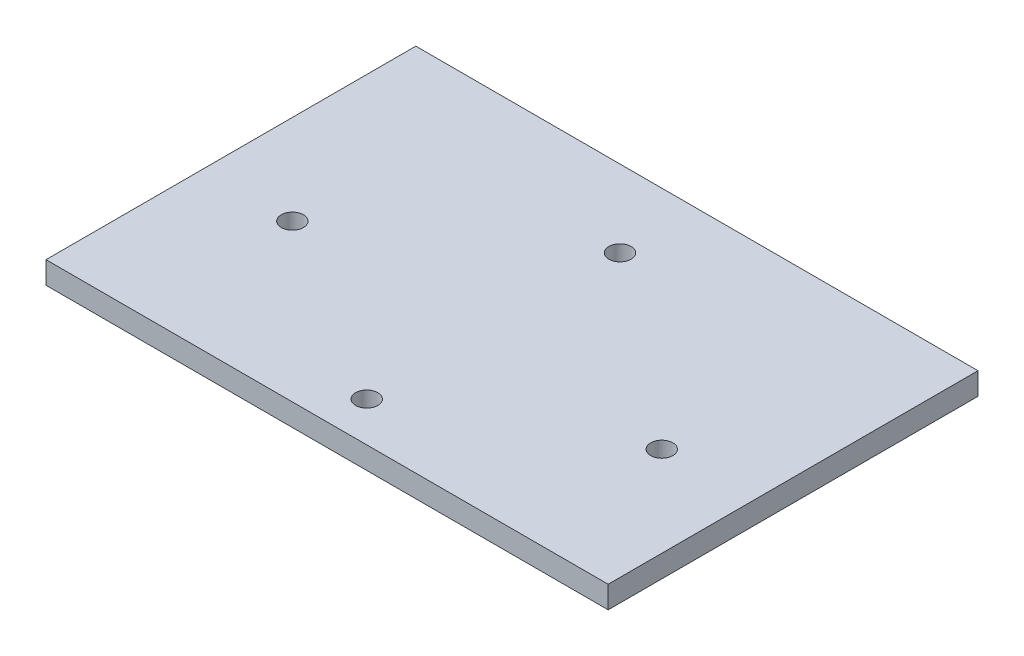
from build123d import *

# Parameters (mm, degrees)
SKETCH2_W           = 76
SKETCH2_H           = 50
SKETCH2_R           = 1.5
BOSS_EXTRUDE1_DEPTH = 3


with BuildPart() as part:
    # Sketch2 → Boss-Extrude1 (new body)
    with BuildSketch(Plane(origin=(0, 0, 0), x_dir=(1, 0, 0), z_dir=(0, 1, 0))):
        Rectangle(SKETCH2_W, SKETCH2_H)
        with Locations((25.816652927, -5.566529266)):
            Circle(SKETCH2_R, mode=Mode.SUBTRACT)
        with Locations((0, 14.599010717)):
            Circle(SKETCH2_R, mode=Mode.SUBTRACT)
        with Locations((-25.857543281, -3.83434903)):
            Circle(SKETCH2_R, mode=Mode.SUBTRACT)
        with Locations((0, -19.640395713)):
            Circle(SKETCH2_R, mode=Mode.SUBTRACT)
    extrude(amount=BOSS_EXTRUDE1_DEPTH)


solid = part.part
